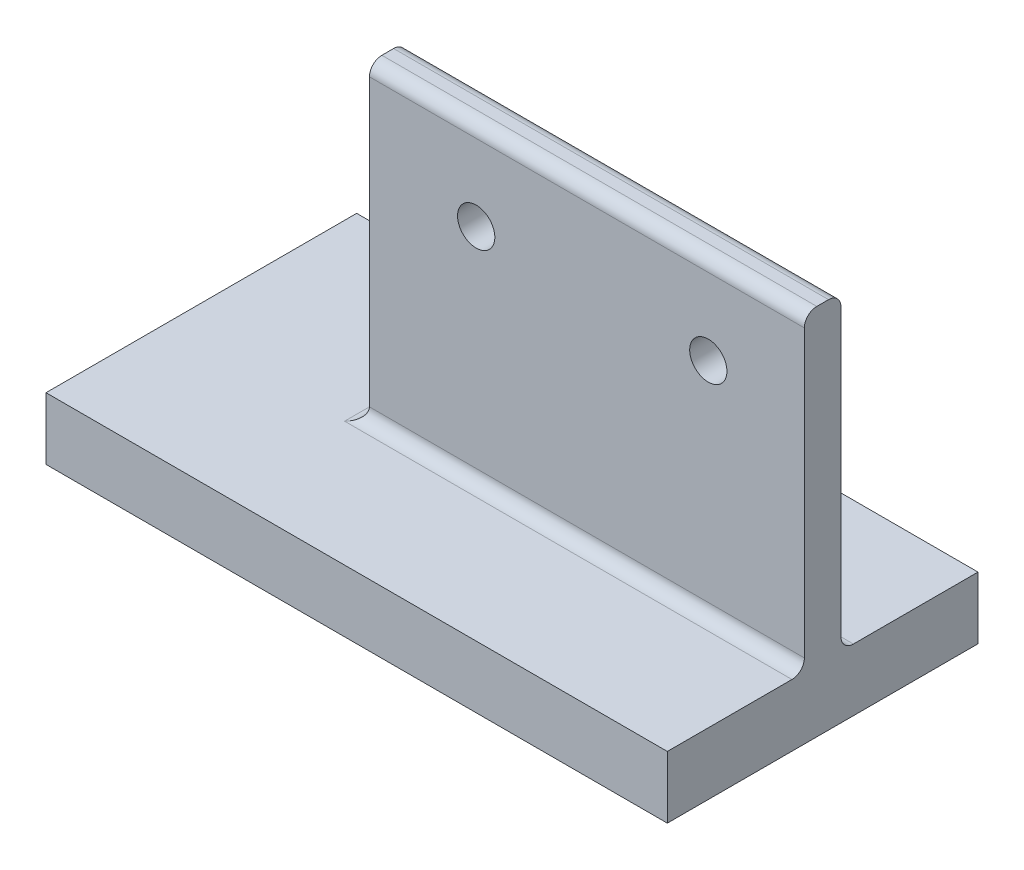
from build123d import *

# Parameters (mm, degrees)
SKETCH1_W               = 100
SKETCH1_H               = 50
BOSS_EXTRUDE1_DEPTH     = 10
SKETCH2_W               = 70
SKETCH2_H               = 5.887144663
BOSS_EXTRUDE2_DEPTH     = 60
SKETCH3_R               = 3
CUT_EXTRUDE1_DEPTH      = 10
CUT_EXTRUDE1_DEPTH_BACK = 10
FILLET1_R               = 2
FILLET2_R               = 2
FILLET3_R               = 2
FILLET4_R               = 2
FILLET5_R               = 2


with BuildPart() as part:
    # Sketch1 → Boss-Extrude1 (new body)
    with BuildSketch(Plane(origin=(0, 0, 0), x_dir=(1, 0, 0), z_dir=(0, 1, 0))):
        with Locations((6.899810964, -1.748582231)):
            Rectangle(SKETCH1_W, SKETCH1_H)
    extrude(amount=BOSS_EXTRUDE1_DEPTH)

    # Sketch2 → Boss-Extrude2 (add)
    with BuildSketch(Plane(origin=(0, 0, 0), x_dir=(1, 0, 0), z_dir=(0, 1, 0))):
        with Locations((21.899810964, -1.748582231)):
            Rectangle(SKETCH2_W, SKETCH2_H)
    extrude(amount=BOSS_EXTRUDE2_DEPTH)

    # Sketch3 → Cut-Extrude1 (cut, two sides)
    with BuildSketch(Plane.XY.offset(4.692154562)) as cut_extrude1_sk:
        with Locations(Location((4.078525913, 45.713993349, 0), (0, 0, 180))):  # turned: the seam where the file's is
            Circle(SKETCH3_R)
        with Locations(Location((41.437726316, 45.713993349, 0), (0, 0, 180))):  # turned: the seam where the file's is
            Circle(SKETCH3_R)
    extrude(amount=CUT_EXTRUDE1_DEPTH, mode=Mode.SUBTRACT)
    extrude(cut_extrude1_sk.sketch, amount=-CUT_EXTRUDE1_DEPTH_BACK, mode=Mode.SUBTRACT)

    # Fillet1
    fillet1_edges = [part.edges().sort_by_distance(p)[0] for p in [
        (21.899810964, 60, 4.692154562),
    ]]
    fillet(fillet1_edges, radius=FILLET1_R)

    # Fillet2
    fillet2_edges = [part.edges().sort_by_distance(p)[0] for p in [
        (21.899810964, 60, -1.194990101),
    ]]
    fillet(fillet2_edges, radius=FILLET2_R)

    # Fillet3
    fillet3_edges = [part.edges().sort_by_distance(p)[0] for p in [
        (21.899810964, 10, -1.194990101),
    ]]
    fillet(fillet3_edges, radius=FILLET3_R)

    # Fillet4
    fillet4_edges = [part.edges().sort_by_distance(p)[0] for p in [
        (21.899810964, 10, 4.692154562),
    ]]
    fillet(fillet4_edges, radius=FILLET4_R)

    # Fillet5
    fillet5_edges = [part.edges().sort_by_distance(p)[0] for p in [
        (-13.100189036, 10, 1.748582231),
    ]]
    fillet(fillet5_edges, radius=FILLET5_R)


solid = part.part
